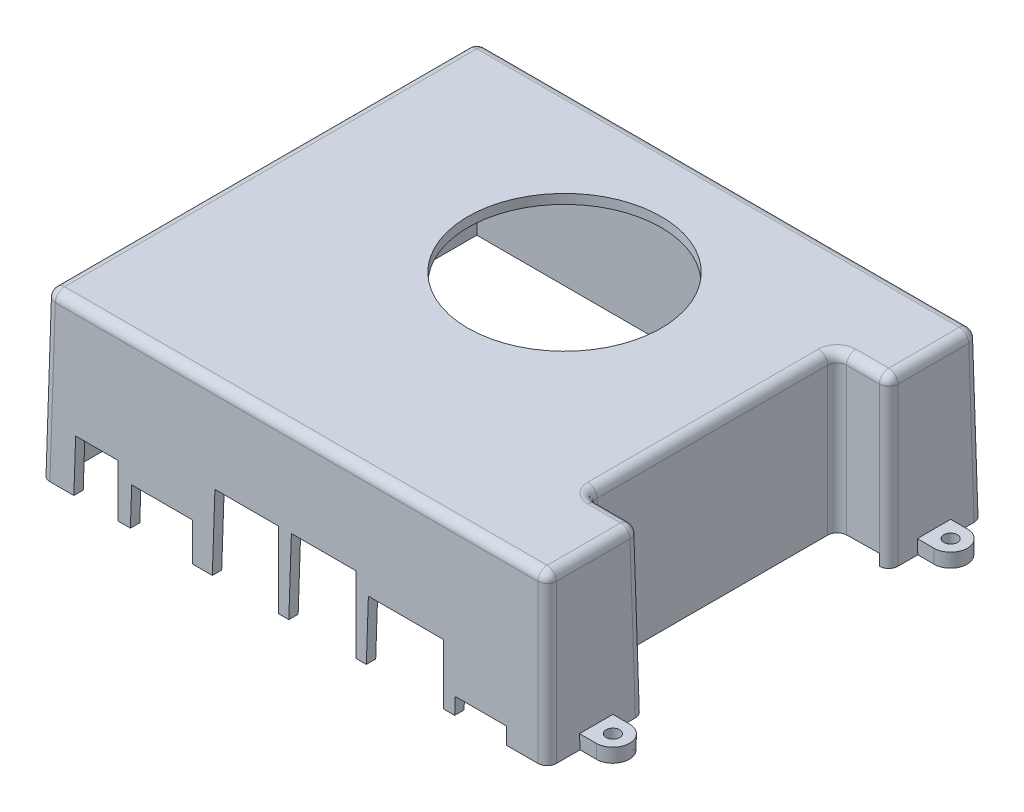
from build123d import *

# Parameters (mm, degrees)
SKETCH2_R               = 20
BOSS_EXTRUDE1_DEPTH     = 35
BOSS_EXTRUDE1_TAPER     = 1
SHELL2_T                = -2
SKETCH8_W               = 9
SKETCH8_H               = 11
SKETCH8_W_2             = 13
SKETCH8_H_2             = 8
SKETCH8_W_3             = 13.5
SKETCH8_H_3             = 15.9
SKETCH8_W_4             = 13.75
SKETCH8_W_5             = 16
SKETCH8_H_4             = 12.6
SKETCH8_W_6             = 10.9
SKETCH8_H_5             = 3.5
CUT_EXTRUDE1_DEPTH      = 2
SKETCH10_R              = 23
CUT_EXTRUDE2_DEPTH      = 35
SKETCH12_W              = 58
SKETCH12_H              = 2.4
CUT_EXTRUDE5_DEPTH      = 8.998325
CUT_EXTRUDE5_DEPTH_BACK = 2
SKETCH13_R              = 1.5
BOSS_EXTRUDE2_DEPTH     = 3
BOSS_EXTRUDE2_TAPER     = -1
FILLET1_R               = 2
CUT_EXTRUDE6_DEPTH      = 3


with BuildPart() as part:
    # Sketch2 → Boss-Extrude1 (new body)
    with BuildSketch(Plane(origin=(0, 0, 0), x_dir=(1, 0, 0), z_dir=(0, 1, 0))):
        Polygon((108, -28.875228514), (97, -28.875228514), (97, 23.124771486), (108, 23.124771486), (108, 43.324771486), (0, 43.324771486), (0, -49.675228514), (108, -49.675228514), align=None)
        with Locations((53.2, 8.824771486)):
            Circle(SKETCH2_R, mode=Mode.SUBTRACT)
    extrude(amount=BOSS_EXTRUDE1_DEPTH, taper=BOSS_EXTRUDE1_TAPER)

    # Shell2
    shell2_openings = [part.faces().sort_by_distance(p)[0] for p in [
        (78.25, 0, 3.025228514),
    ]]
    offset(amount=SHELL2_T, openings=shell2_openings, kind=Kind.INTERSECTION)

    # Sketch8 → Cut-Extrude1 (cut)
    with BuildSketch(Plane(origin=(0, 0.866820237, 49.660098111), x_dir=(1, 0, 0), z_dir=(0, 0.017452406, 0.999847695))):
        with Locations((11.8, 4.633047722)):
            Rectangle(SKETCH8_W, SKETCH8_H)
        with Locations((25.8, 3.133047722)):
            Rectangle(SKETCH8_W_2, SKETCH8_H_2)
        with Locations((43.65, 7.083047722)):
            Rectangle(SKETCH8_W_3, SKETCH8_H_3)
        with Locations((60.075, 7.083047722)):
            Rectangle(SKETCH8_W_4, SKETCH8_H_3)
        with Locations((77.666481236, 5.433047722)):
            Rectangle(SKETCH8_W_5, SKETCH8_H_4)
        with Locations((93.796481236, 0.883047722)):
            Rectangle(SKETCH8_W_6, SKETCH8_H_5)
    extrude(amount=-CUT_EXTRUDE1_DEPTH, mode=Mode.SUBTRACT)

    # Sketch10 → Cut-Extrude2 (cut)
    with BuildSketch(Plane(origin=(0, 33, 0), x_dir=(-1, 0, 0), z_dir=(0, -1, 0))):
        with Locations((-53.2, 8.824771486)):
            Circle(SKETCH10_R)
    extrude(amount=CUT_EXTRUDE2_DEPTH, mode=Mode.SUBTRACT)

    # Sketch12 → Cut-Extrude5 (cut, two sides)
    with BuildSketch(Plane(origin=(96.97045511, 1.69262559, 0), x_dir=(0, 0, -1), z_dir=(0.999847695, 0.017452406, 0))) as cut_extrude5_sk:
        with Locations((-3.075228514, -0.692883424)):
            Rectangle(SKETCH12_W, SKETCH12_H)
    extrude(amount=CUT_EXTRUDE5_DEPTH, mode=Mode.SUBTRACT)
    extrude(cut_extrude5_sk.sketch, amount=-CUT_EXTRUDE5_DEPTH_BACK, mode=Mode.SUBTRACT)

    # Sketch13 → Boss-Extrude2 (add)
    with BuildSketch(Plane(origin=(0, 0, 0), x_dir=(-1, 0, 0), z_dir=(0, -1, 0))):
        with BuildLine():
            Line((-111.5, -42.674923858), (-105.999695344, -42.674923858))
            Line((-105.999695344, -42.674923858), (-105.999695344, -35.674923858))
            Line((-105.999695344, -35.674923858), (-111.5, -35.674923858))
            ThreePointArc((-111.5, -35.674923858), (-115, -39.174923858), (-111.5, -42.674923858))
        make_face()
        with Locations((-111.5, -39.174923858)):
            Circle(SKETCH13_R, mode=Mode.SUBTRACT)
        with BuildLine():
            Line((-111.499695344, 29.324466829), (-105.999695344, 29.324466829))
            Line((-105.999695344, 29.324466829), (-105.999695344, 36.324466829))
            Line((-105.999695344, 36.324466829), (-111.499695344, 36.324466829))
            ThreePointArc((-111.499695344, 36.324466829), (-114.999695344, 32.824466829), (-111.499695344, 29.324466829))
        make_face()
        with Locations((-111.499695344, 32.824466829)):
            Circle(SKETCH13_R, mode=Mode.SUBTRACT)
        with BuildLine():
            ThreePointArc((3.5, 29.324466829), (7, 32.824466829), (3.5, 36.324466829))
            Line((3.5, 36.324466829), (-2.000304656, 36.324466829))
            Line((-2.000304656, 36.324466829), (-2.000304656, 29.324466829))
            Line((-2.000304656, 29.324466829), (3.5, 29.324466829))
        make_face()
        with Locations((3.5, 32.824466829)):
            Circle(SKETCH13_R, mode=Mode.SUBTRACT)
        with BuildLine():
            ThreePointArc((3.5, -42.674923858), (7, -39.174923858), (3.5, -35.674923858))
            Line((3.5, -35.674923858), (-2.000304656, -35.674923858))
            Line((-2.000304656, -35.674923858), (-2.000304656, -42.674923858))
            Line((-2.000304656, -42.674923858), (3.5, -42.674923858))
        make_face()
        with Locations((3.5, -39.174923858)):
            Circle(SKETCH13_R, mode=Mode.SUBTRACT)
    extrude(amount=-BOSS_EXTRUDE2_DEPTH, taper=BOSS_EXTRUDE2_TAPER)

    # Fillet1
    fillet1_edges = [part.edges().sort_by_distance(p)[0] for p in [
        (107.389072728, 35, 39.275228514),
        (0.305463636, 17.5, -43.019307849),
        (107.694536364, 17.5, -43.019307849),
        (107.694536364, 17.5, -23.430235122),
        (96.675338717, 18.599832465, -23.449432769),
        (96.675338717, 18.599832465, 29.199889798),
        (107.694536364, 17.5, 29.180692151),
        (107.694536364, 17.5, 49.369764878),
        (0.305463636, 17.5, 49.369764878),
        (101.889072728, 35, 29.486155787),
        (96.389072728, 35, 2.875228514),
        (101.889072728, 35, -23.735698758),
        (107.389072728, 35, -33.224771486),
        (54, 35, -42.713844213),
        (0.610927272, 35, 3.175228514),
        (54, 35, 49.064301242),
    ]]
    fillet(fillet1_edges, radius=FILLET1_R)

    # Sketch14 → Cut-Extrude6 (cut)
    with BuildSketch(Plane(origin=(0, 0.866820237, 49.660098111), x_dir=(1, 0, 0), z_dir=(0, 0.017452406, 0.999847695))):
        Polygon((7.3, 10.133047722), (7.107994286, -0.866952278), (16.492005714, -0.866952278), (16.3, 10.133047722), align=None)
        Polygon((19.3, 7.133047722), (32.3, 7.133047722), (32.439640519, -0.866952278), (19.160359481, -0.866952278), align=None)
        Polygon((36.622464468, -0.866952278), (36.9, 15.033047722), (50.4, 15.033047722), (50.677535532, -0.866952278), align=None)
        Polygon((66.95, 15.033047722), (67.227535532, -0.866952278), (52.922464468, -0.866952278), (53.2, 15.033047722), align=None)
        Polygon((69.666481236, 11.733047722), (69.448918772, -0.866952278), (85.886415054, -0.866952278), (85.666481236, 11.733047722), align=None)
        Polygon((88.285388508, -0.866952278), (88.346481236, 2.633047722), (99.246481236, 2.633047722), (99.307573963, -0.866952278), align=None)
    extrude(amount=-CUT_EXTRUDE6_DEPTH, mode=Mode.SUBTRACT)


solid = part.part
